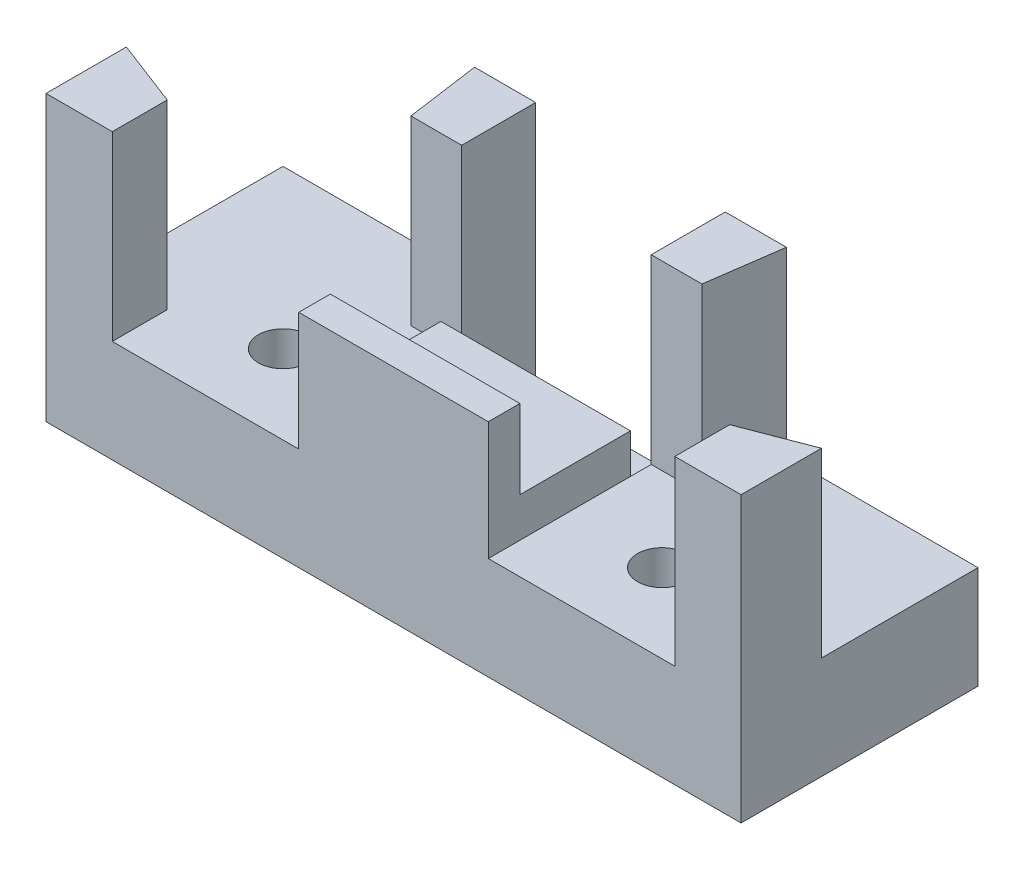
from build123d import *

# Parameters (mm, degrees)
SKETCH1_W           = 44
SKETCH1_H           = 15
BOSS_EXTRUDE1_DEPTH = 5
SKETCH2_W           = 12
SKETCH2_H           = 15
BOSS_EXTRUDE2_DEPTH = 4
SKETCH3_R           = 1.55
CUT_EXTRUDE1_DEPTH  = 3
SKETCH4_R           = 1.55
CUT_EXTRUDE2_DEPTH  = 3
SKETCH6_W           = 12
SKETCH6_H           = 2
BOSS_EXTRUDE4_DEPTH = 5
BOSS_EXTRUDE5_DEPTH = 13
SKETCH10_W          = 12
SKETCH10_H          = 6
CUT_EXTRUDE4_DEPTH  = 7
SKETCH11_R          = 1.55
BOSS_EXTRUDE6_DEPTH = 1.5


with BuildPart() as part:
    # Sketch1 → Boss-Extrude1 (new body)
    with BuildSketch(Plane(origin=(0, 0, 0), x_dir=(1, 0, 0), z_dir=(0, 1, 0))):
        with Locations((22, -7.5)):
            Rectangle(SKETCH1_W, SKETCH1_H)
    extrude(amount=BOSS_EXTRUDE1_DEPTH)

    # Sketch2 → Boss-Extrude2 (add)
    with BuildSketch(Plane(origin=(0, 5, 0), x_dir=(1, 0, 0), z_dir=(0, 1, 0))):
        with Locations((22, -7.5)):
            Rectangle(SKETCH2_W, SKETCH2_H)
    extrude(amount=BOSS_EXTRUDE2_DEPTH)

    # Sketch3 → Cut-Extrude1 (cut)
    with BuildSketch(Plane(origin=(0, 5, 0), x_dir=(1, 0, 0), z_dir=(0, 1, 0))):
        with Locations((10, -10)):
            Circle(SKETCH3_R)
        with Locations((34, -10)):
            Circle(SKETCH3_R)
    extrude(amount=-CUT_EXTRUDE1_DEPTH, mode=Mode.SUBTRACT)

    # Sketch4 → Cut-Extrude2 (cut)
    with BuildSketch(Plane(origin=(0, 9, 0), x_dir=(1, 0, 0), z_dir=(0, 1, 0))):
        with Locations((22, -10)):
            Circle(SKETCH4_R)
    extrude(amount=-CUT_EXTRUDE2_DEPTH, mode=Mode.SUBTRACT)

    # Sketch6 → Boss-Extrude4 (add)
    with BuildSketch(Plane(origin=(0, 9, 0), x_dir=(1, 0, 0), z_dir=(0, 1, 0))):
        with Locations((22, -14)):
            Rectangle(SKETCH6_W, SKETCH6_H)
    extrude(amount=BOSS_EXTRUDE4_DEPTH)

    # Sketch8 → Boss-Extrude5 (add)
    with BuildSketch(Plane(origin=(0, 5, 0), x_dir=(1, 0, 0), z_dir=(0, 1, 0))):
        Polygon((31.212307556, -4.686924541), (31.871011843, 0), (28, 0), (28, -4.686924541), align=None)
        Polygon((39.803996034, -11.521062141), (44, -9.910367127), (44, -15), (39.803996034, -15), align=None)
        Polygon((12.787692444, -4.686924541), (12.128988157, 0), (16, 0), (16, -4.686924541), align=None)
        Polygon((4.196003966, -11.521062141), (0, -9.910367127), (0, -15), (4.196003966, -15), align=None)
    extrude(amount=BOSS_EXTRUDE5_DEPTH)

    # Sketch10 → Cut-Extrude4 (cut)
    with BuildSketch(Plane(origin=(0, 9, 0), x_dir=(1, 0, 0), z_dir=(0, 1, 0))):
        with Locations((22, -3)):
            Rectangle(SKETCH10_W, SKETCH10_H)
    extrude(amount=-CUT_EXTRUDE4_DEPTH, mode=Mode.SUBTRACT)

    # Sketch11 → Boss-Extrude6 (add)
    with BuildSketch(Plane(origin=(0, 5, 0), x_dir=(1, 0, 0), z_dir=(0, 1, 0))):
        Polygon((16, -15), (16, -4.686924541), (12.787692444, -4.686924541), (12.128988157, 0), (0, 0), (0, -9.910367127), (4.196003966, -11.521062141), (4.196003966, -15), align=None)
        with Locations((10, -10)):
            Circle(SKETCH11_R, mode=Mode.SUBTRACT)
        Polygon((39.803996034, -11.521062141), (39.803996034, -15), (28, -15), (28, -4.686924541), (31.212307556, -4.686924541), (31.871011843, 0), (44, 0), (44, -9.910367127), align=None)
        with Locations((34, -10)):
            Circle(SKETCH11_R, mode=Mode.SUBTRACT)
    extrude(amount=BOSS_EXTRUDE6_DEPTH)


solid = part.part
